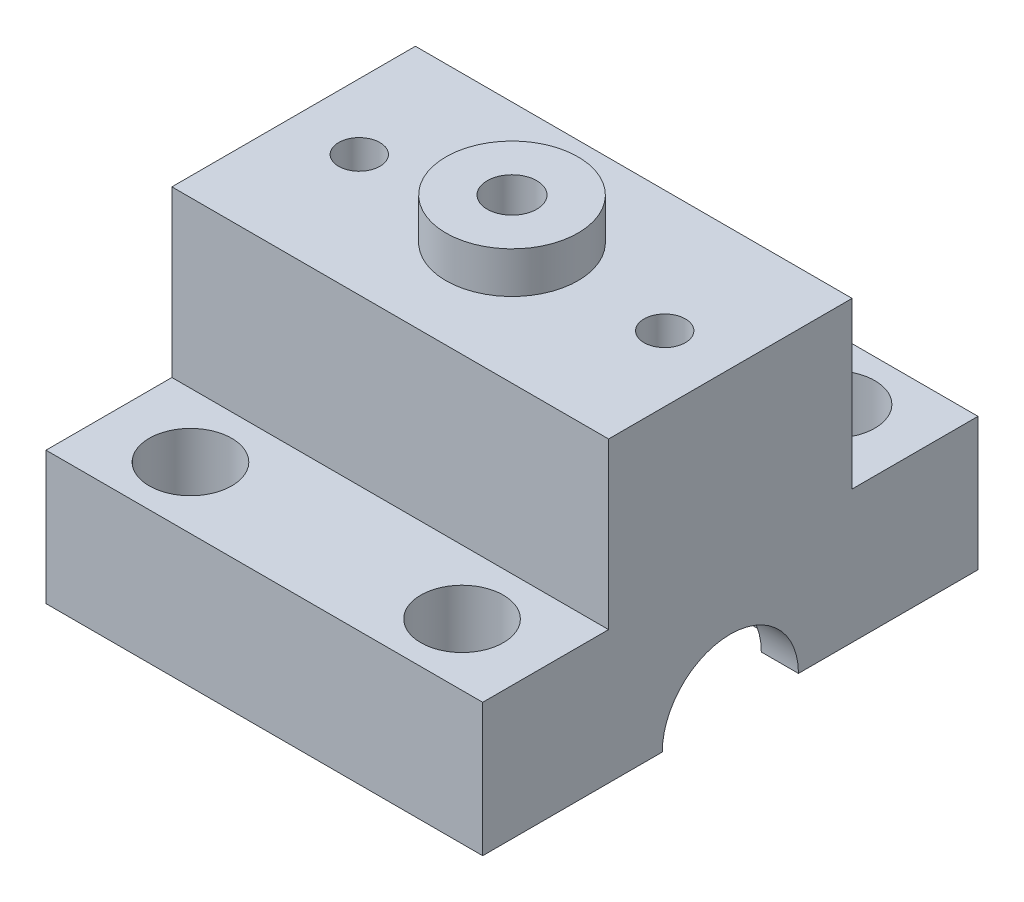
from build123d import *

# Parameters (mm, degrees)
SKETCH1_W             = 52.9
SKETCH1_H             = 30
SKETCH1_R             = 10.25
BOSS_EXTRUDE1_DEPTH   = 5
SKETCH2_W             = 52.9
SKETCH2_H             = 30
SKETCH2_W_2           = 43.9
SKETCH2_H_2           = 21
BOSS_EXTRUDE2_DEPTH   = 11.1
SKETCH3_R             = 8.25
CUT_EXTRUDE1_DEPTH    = 53.9
SKETCH4_W             = 52.9
SKETCH4_H             = 5
BOSS_EXTRUDE3_DEPTH   = 15
SKETCH5_W             = 52.9
SKETCH5_H             = 5
BOSS_EXTRUDE4_DEPTH   = 15
SKETCH7_R             = 14.75
SKETCH7_R_2           = 10.25
BOSS_EXTRUDE5_DEPTH   = 15
SKETCH8_R             = 14.75
SKETCH8_R_2           = 1.65
BOSS_EXTRUDE6_DEPTH   = 5
SKETCH9_R             = 8
SKETCH9_R_2           = 3
BOSS_EXTRUDE7_DEPTH   = 5
SKETCH10_W            = 52.9
SKETCH10_H            = 15
BOSS_EXTRUDE8_DEPTH   = 11.1
SKETCH12_R            = 5
CUT_EXTRUDE2_DEPTH    = 8
SKETCH13_R            = 2.2
CUT_EXTRUDE3_DEPTH    = 9.1
BOSS_EXTRUDE11_DEPTH  = 20
SKETCH16_R            = 2.5
CUT_EXTRUDE4_DEPTH    = 5
M3_TAPPED_HOLE1_D     = 2.5
M3_TAPPED_HOLE1_DEPTH = 10.748924226
M3_TAPPED_HOLE1_TIP   = 0.751075774


with BuildPart() as part:
    # Sketch1 → Boss-Extrude1 (new body)
    with BuildSketch(Plane(origin=(0, 0, 0), x_dir=(1, 0, 0), z_dir=(0, 1, 0))):
        Rectangle(SKETCH1_W, SKETCH1_H)
        Circle(SKETCH1_R, mode=Mode.SUBTRACT)
    extrude(amount=BOSS_EXTRUDE1_DEPTH)

    # Sketch2 → Boss-Extrude2 (add)
    with BuildSketch(Plane.XZ):
        Rectangle(SKETCH2_W, SKETCH2_H)
        Rectangle(SKETCH2_W_2, SKETCH2_H_2, mode=Mode.SUBTRACT)
    extrude(amount=BOSS_EXTRUDE2_DEPTH)

    # Sketch3 → Cut-Extrude1 (cut, through all)
    with BuildSketch(Plane(origin=(26.45, 0, 0), x_dir=(0, 0, -1), z_dir=(1, 0, 0))):
        with Locations((0, -11.1)):
            Circle(SKETCH3_R)
    extrude(amount=-CUT_EXTRUDE1_DEPTH, mode=Mode.SUBTRACT)

    # Sketch4 → Boss-Extrude3 (add)
    with BuildSketch(Plane(origin=(0, 0, -15), x_dir=(-1, 0, 0), z_dir=(0, 0, -1))):
        with Locations((0, -8.6)):
            Rectangle(SKETCH4_W, SKETCH4_H)
    extrude(amount=BOSS_EXTRUDE3_DEPTH)

    # Sketch5 → Boss-Extrude4 (add)
    with BuildSketch(Plane.XY.offset(15)):
        with Locations((0, -8.6)):
            Rectangle(SKETCH5_W, SKETCH5_H)
    extrude(amount=BOSS_EXTRUDE4_DEPTH)

    # Sketch7 → Boss-Extrude5 (add)
    with BuildSketch(Plane(origin=(0, 5, 0), x_dir=(1, 0, 0), z_dir=(0, 1, 0))):
        Circle(SKETCH7_R)
        Circle(SKETCH7_R_2, mode=Mode.SUBTRACT)
    extrude(amount=BOSS_EXTRUDE5_DEPTH)

    # Sketch8 → Boss-Extrude6 (add)
    with BuildSketch(Plane(origin=(0, 20, 0), x_dir=(1, 0, 0), z_dir=(0, 1, 0))):
        Circle(SKETCH8_R)
        Circle(SKETCH8_R_2, mode=Mode.SUBTRACT)
    extrude(amount=BOSS_EXTRUDE6_DEPTH)

    # Sketch9 → Boss-Extrude7 (add)
    with BuildSketch(Plane(origin=(0, 25, 0), x_dir=(1, 0, 0), z_dir=(0, 1, 0))):
        Circle(SKETCH9_R)
        Circle(SKETCH9_R_2, mode=Mode.SUBTRACT)
    extrude(amount=BOSS_EXTRUDE7_DEPTH)

    # Sketch10 → Boss-Extrude8 (add)
    with BuildSketch(Plane(origin=(0, -6.1, 0), x_dir=(1, 0, 0), z_dir=(0, 1, 0))):
        with Locations((0, 22.5)):
            Rectangle(SKETCH10_W, SKETCH10_H)
        with Locations((0, -22.5)):
            Rectangle(SKETCH10_W, SKETCH10_H)
    extrude(amount=BOSS_EXTRUDE8_DEPTH)

    # Sketch12 → Cut-Extrude2 (cut)
    with BuildSketch(Plane(origin=(0, 5, 0), x_dir=(1, 0, 0), z_dir=(0, 1, 0))):
        with Locations((-16.45, -22.5)):
            Circle(SKETCH12_R)
        with Locations((16.45, -22.5)):
            Circle(SKETCH12_R)
        with Locations((16.45, 22.5)):
            Circle(SKETCH12_R)
        with Locations((-16.45, 22.5)):
            Circle(SKETCH12_R)
    extrude(amount=-CUT_EXTRUDE2_DEPTH, mode=Mode.SUBTRACT)

    # Sketch13 → Cut-Extrude3 (cut, through all)
    with BuildSketch(Plane(origin=(0, -3, 0), x_dir=(1, 0, 0), z_dir=(0, 1, 0))):
        with Locations((-16.45, -22.5)):
            Circle(SKETCH13_R)
        with Locations((-16.45, 22.5)):
            Circle(SKETCH13_R)
        with Locations((16.45, 22.5)):
            Circle(SKETCH13_R)
        with Locations((16.45, -22.5)):
            Circle(SKETCH13_R)
    extrude(amount=-CUT_EXTRUDE3_DEPTH, mode=Mode.SUBTRACT)

    # Sketch14 → Boss-Extrude11 (add)
    with BuildSketch(Plane(origin=(0, 5, 0), x_dir=(1, 0, 0), z_dir=(0, 1, 0))):
        with BuildLine():
            Line((-26.45, 14.75), (-26.45, -14.75))
            Line((-26.45, -14.75), (4e-09, -14.75))
            ThreePointArc((4e-09, -14.75), (-14.75, -5e-09), (-6e-09, 14.75))
            Line((-6e-09, 14.75), (-26.45, 14.75))
        make_face()
        with BuildLine():
            ThreePointArc((14.75, 0), (10.429825024, -10.429825021), (4e-09, -14.75))
            Line((4e-09, -14.75), (26.45, -14.75))
            Line((26.45, -14.75), (26.45, 14.75))
            Line((26.45, 14.75), (-6e-09, 14.75))
            ThreePointArc((-6e-09, 14.75), (10.42982502, 10.429825025), (14.75, 0))
        make_face()
    extrude(amount=BOSS_EXTRUDE11_DEPTH)

    # Sketch16 → Cut-Extrude4 (cut)
    with BuildSketch(Plane(origin=(0, 25, 0), x_dir=(1, 0, 0), z_dir=(0, 1, 0))):
        with Locations((18.5, 0)):
            Circle(SKETCH16_R)
        with Locations((-18.5, 0)):
            Circle(SKETCH16_R)
    extrude(amount=-CUT_EXTRUDE4_DEPTH, mode=Mode.SUBTRACT)

    # M3 Tapped Hole1
    with Locations(Plane(origin=(0, 20, 0), x_dir=(1, 0, 0), z_dir=(0, 1, 0))):
        with Locations((-18.5, 0), (18.5, 0)):
            Hole(M3_TAPPED_HOLE1_D / 2, depth=M3_TAPPED_HOLE1_DEPTH)
            with Locations((0, 0, -(M3_TAPPED_HOLE1_DEPTH + M3_TAPPED_HOLE1_TIP / 2))):  # 118° drill point
                Cone(0, M3_TAPPED_HOLE1_D / 2, M3_TAPPED_HOLE1_TIP, mode=Mode.SUBTRACT)


solid = part.part
